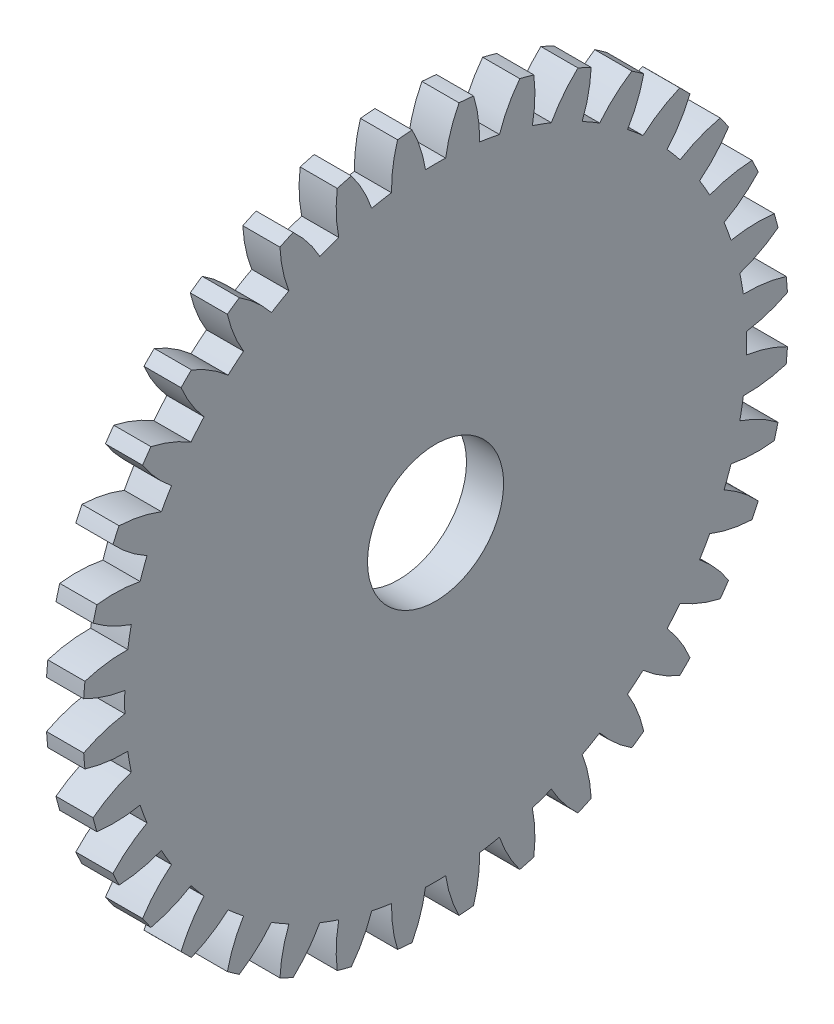
from build123d import *

# Parameters (mm, degrees)
BASPROSKE_W     = 6
BASPROSKE_H     = 57
TOOTHCUT_DEPTH  = 81.833161512
TEETHCUTS_COUNT = 36
TEETHCUTS_ANGLE = 350
BORSKE_R        = 11
BORE_DEPTH      = 50.0000508


with BuildPart() as part:
    # BasProSke → Base-Revolve (revolve)
    with BuildSketch(Plane(origin=(0, 0, 0), x_dir=(1, 0, 0), z_dir=(0, 1, 0)), mode=Mode.PRIVATE) as base_revolve_sk:
        with Locations((3, 28.5)):
            Rectangle(BASPROSKE_W, BASPROSKE_H)
    revolve(base_revolve_sk.sketch.rotate(Axis((-10, 0, 0), (1, 0, 0)), 180), axis=Axis((-10, 0, 0), (1, 0, 0)))

    # TooCutSke → ToothCut (cut, through all)
    with BuildSketch(Plane(origin=(0, 0, 0), x_dir=(0, 0, -1), z_dir=(1, 0, 0))):
        with BuildLine():
            ThreePointArc((1.631054659, 50.222521459), (0, 50.249), (-1.631054659, 50.222521459))
            ThreePointArc((-1.631054659, 50.222521459), (-2.445638595, 53.649350602), (-3.806344838, 56.898224789))
            ThreePointArc((-3.806344838, 56.898224789), (0, 57.0254), (3.806344838, 56.898224789))
            ThreePointArc((3.806344838, 56.898224789), (2.445638595, 53.649350602), (1.631054659, 50.222521459))
        make_face()
    toothcut = extrude(amount=TOOTHCUT_DEPTH, mode=Mode.SUBTRACT)

    # TeethCuts: ToothCut ×36 about axis
    teethcuts_axis = Axis((-10, 0, 0), (1, 0, 0))
    for i in range(1, TEETHCUTS_COUNT):
        add(toothcut.rotate(teethcuts_axis, i * TEETHCUTS_ANGLE / (TEETHCUTS_COUNT - 1)), mode=Mode.SUBTRACT)

    # BorSke → Bore (cut, symmetric)
    with BuildSketch(Plane(origin=(0, 0, 0), x_dir=(0, 0, -1), z_dir=(1, 0, 0))):
        with Locations(Location((0, 0, 0), (0, 0, 180))):
            Circle(BORSKE_R)
    extrude(amount=BORE_DEPTH, both=True, mode=Mode.SUBTRACT)


solid = part.part
